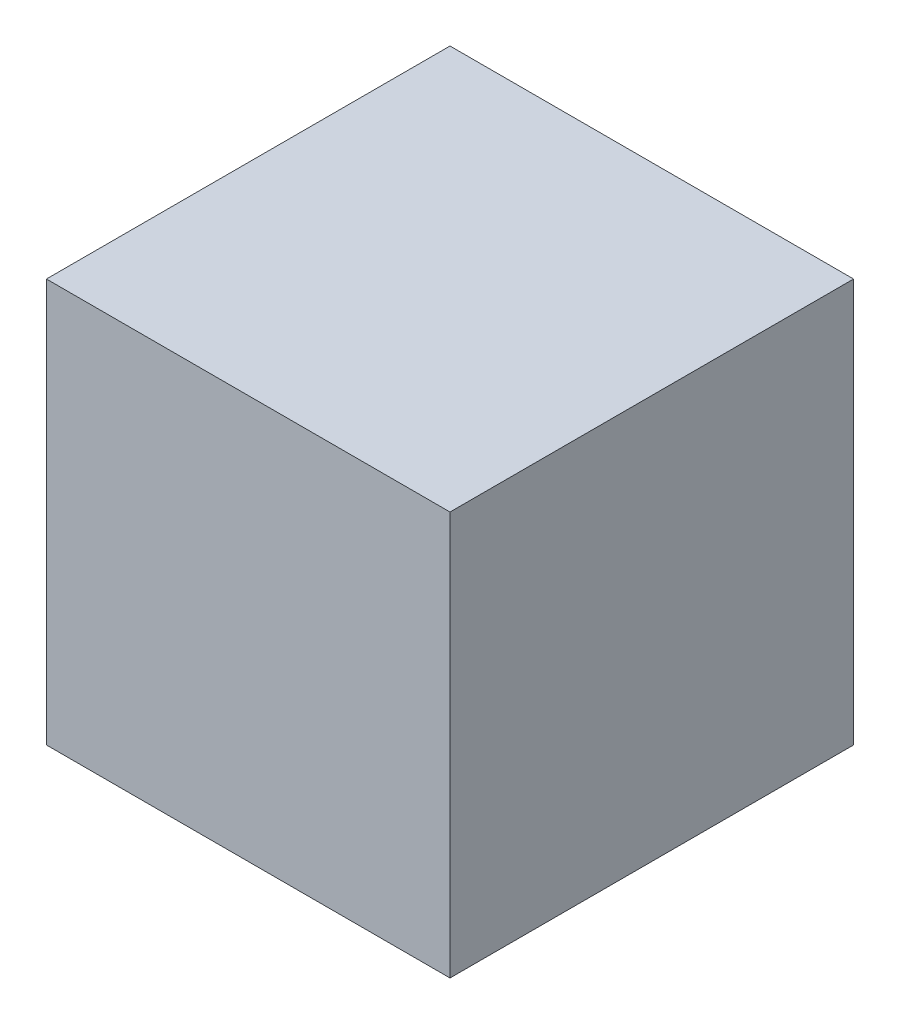
from build123d import *

# Parameters (mm, degrees)
SKETCH_2_W      = 10
SKETCH_2_H      = 10
EXTRUDE_1_DEPTH = 10


with BuildPart() as part:
    # ｽｹｯﾁ2 → ﾎﾞｽ - 押し出し1 (new body)
    with BuildSketch(Plane.XY):
        with Locations((5, 5)):
            Rectangle(SKETCH_2_W, SKETCH_2_H)
    extrude(amount=EXTRUDE_1_DEPTH)


solid = part.part
